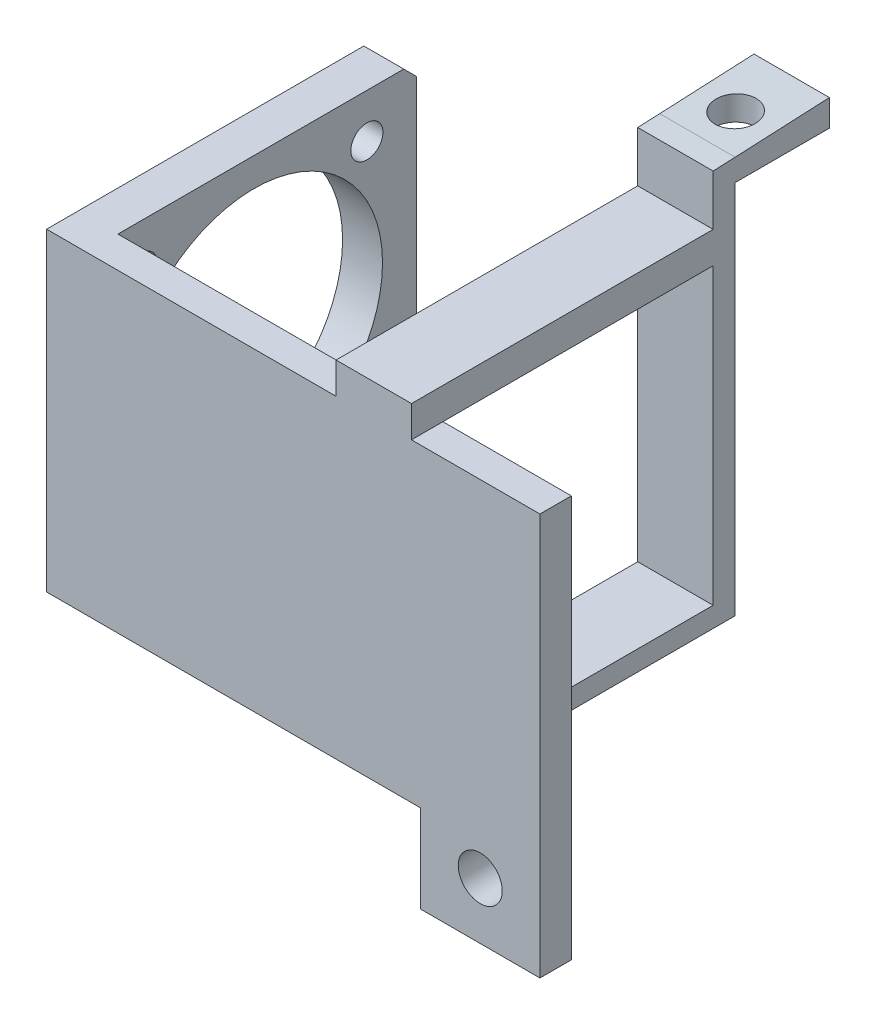
from build123d import *

# Parameters (mm, degrees)
BOSS_EXTRUDE1_DEPTH  = 5
SKETCH2_W            = 6.35
SKETCH2_H            = 50
BOSS_EXTRUDE2_DEPTH  = 52.48
CUT_EXTRUDE1_REACH   = 111.834
SKETCH3_R            = 20.44
SKETCH3_R_2          = 2.555
SKETCH3_W            = 5
SKETCH3_H            = 50
CUT_EXTRUDE2_REACH   = 113.895
SKETCH4_R            = 3.5
CUT_EXTRUDE6_REACH   = 113.895
SKETCH14_W           = 19
SKETCH14_H           = 15.316152196
SKETCH15_W           = 12
SKETCH15_H           = 3.2
BOSS_EXTRUDE7_DEPTH  = 46.5
BOSS_EXTRUDE8_REACH  = 107.356
SKETCH16_W           = 12
SKETCH16_H           = 3.5
SKETCH17_W           = 12
SKETCH17_H           = 3.5
BOSS_EXTRUDE9_DEPTH  = 15
CHAMFER2_SIZE        = 2
SKETCH22_W           = 12
SKETCH22_H           = 15
BOSS_EXTRUDE10_DEPTH = 0.72
CUT_EXTRUDE8_REACH   = 108.012
CUT_EXTRUDE7_REACH   = 125.963
SKETCH18_R           = 3.25
CIRPATTERN2_COUNT    = 2
CIRPATTERN2_ANGLE    = 90
BOSS_EXTRUDE11_REACH = 120.448
SKETCH24_W           = 12
SKETCH24_H           = 5


with BuildPart() as part:
    # Sketch1 → Boss-Extrude1 (new body)
    with BuildSketch(Plane.XY):
        Polygon((0, 0), (0, 50), (46.06, 50), (46.06, 55), (58.06, 55), (58.06, 50), (59.5, 50), (59.5, 64.061014889), (78.5, 64.061014889), (78.5, -13.938985111), (59.5, -13.938985111), (59.5, 0), align=None)
    extrude(amount=BOSS_EXTRUDE1_DEPTH)

    # Sketch2 → Boss-Extrude2 (add)
    with BuildSketch(Plane(origin=(0, 0, 0), x_dir=(-1, 0, 0), z_dir=(0, 0, -1))):
        with Locations((-3.175, 25)):
            Rectangle(SKETCH2_W, SKETCH2_H)
    extrude(amount=BOSS_EXTRUDE2_DEPTH)

    # Sketch3 → Cut-Extrude1 (cut, up to next)
    with BuildSketch(Plane(origin=(6.35, 0, 0), x_dir=(0, 0, -1), z_dir=(1, 0, 0)), mode=Mode.PRIVATE) as cut_extrude1_sk1:
        with Locations((21.66, 25)):
            Circle(SKETCH3_R)
    cut_extrude1_tool1 = extrude(cut_extrude1_sk1.sketch, amount=-CUT_EXTRUDE1_REACH, mode=Mode.PRIVATE) & part.part
    # Sketch3 → Cut-Extrude1 (cut, up to next)
    with BuildSketch(Plane(origin=(6.35, 0, 0), x_dir=(0, 0, -1), z_dir=(1, 0, 0)), mode=Mode.PRIVATE) as cut_extrude1_sk2:
        with Locations((3.695, 42.955)):
            Circle(SKETCH3_R_2)
    cut_extrude1_tool2 = extrude(cut_extrude1_sk2.sketch, amount=-CUT_EXTRUDE1_REACH, mode=Mode.PRIVATE) & part.part
    # Sketch3 → Cut-Extrude1 (cut, up to next)
    with BuildSketch(Plane(origin=(6.35, 0, 0), x_dir=(0, 0, -1), z_dir=(1, 0, 0)), mode=Mode.PRIVATE) as cut_extrude1_sk3:
        with Locations((39.615, 7.045)):
            Circle(SKETCH3_R_2)
    cut_extrude1_tool3 = extrude(cut_extrude1_sk3.sketch, amount=-CUT_EXTRUDE1_REACH, mode=Mode.PRIVATE) & part.part
    # Sketch3 → Cut-Extrude1 (cut, up to next)
    with BuildSketch(Plane(origin=(6.35, 0, 0), x_dir=(0, 0, -1), z_dir=(1, 0, 0)), mode=Mode.PRIVATE) as cut_extrude1_sk4:
        with Locations((49.98, 25)):
            Rectangle(SKETCH3_W, SKETCH3_H)
    cut_extrude1_tool4 = extrude(cut_extrude1_sk4.sketch, amount=-CUT_EXTRUDE1_REACH, mode=Mode.PRIVATE) & part.part
    cut_extrude1_1 = cut_extrude1_tool1.solids().sort_by_distance((6.35, 25, -21.66))[0]
    add(cut_extrude1_1, mode=Mode.SUBTRACT)
    cut_extrude1_2 = cut_extrude1_tool2.solids().sort_by_distance((6.35, 42.955, -3.695))[0]
    add(cut_extrude1_2, mode=Mode.SUBTRACT)
    cut_extrude1_3 = cut_extrude1_tool3.solids().sort_by_distance((6.35, 7.045, -39.615))[0]
    add(cut_extrude1_3, mode=Mode.SUBTRACT)
    cut_extrude1_4 = cut_extrude1_tool4.solids().sort_by_distance((6.35, 25, -49.98))[0]
    add(cut_extrude1_4, mode=Mode.SUBTRACT)
    cut_extrude1 = cut_extrude1_1 + cut_extrude1_2 + cut_extrude1_3 + cut_extrude1_4  # Cut-Extrude1 as one shape, for the pattern or mirror that repeats it

    # Sketch4 → Cut-Extrude2 (cut, up to next)
    with BuildSketch(Plane(origin=(0, 0, 0), x_dir=(-1, 0, 0), z_dir=(0, 0, -1)), mode=Mode.PRIVATE) as cut_extrude2_sk1:
        with Locations((-69, 55.061014889)):
            Circle(SKETCH4_R)
    cut_extrude2_tool1 = extrude(cut_extrude2_sk1.sketch, amount=-CUT_EXTRUDE2_REACH, mode=Mode.PRIVATE) & part.part
    # Sketch4 → Cut-Extrude2 (cut, up to next)
    with BuildSketch(Plane(origin=(0, 0, 0), x_dir=(-1, 0, 0), z_dir=(0, 0, -1)), mode=Mode.PRIVATE) as cut_extrude2_sk2:
        with Locations((-69, -4.938985111)):
            Circle(SKETCH4_R)
    cut_extrude2_tool2 = extrude(cut_extrude2_sk2.sketch, amount=-CUT_EXTRUDE2_REACH, mode=Mode.PRIVATE) & part.part
    add(cut_extrude2_tool1.solids().sort_by_distance((69, 55.061015, 0))[0], mode=Mode.SUBTRACT)
    add(cut_extrude2_tool2.solids().sort_by_distance((69, -4.938985, 0))[0], mode=Mode.SUBTRACT)

    # Sketch14 → Cut-Extrude6 (cut, up to next)
    with BuildSketch(Plane(origin=(0, 0, 0), x_dir=(-1, 0, 0), z_dir=(0, 0, -1)), mode=Mode.PRIVATE) as cut_extrude6_sk1:
        with Locations((-69, 57.658076098)):
            Rectangle(SKETCH14_W, SKETCH14_H)
    cut_extrude6_tool1 = extrude(cut_extrude6_sk1.sketch, amount=-CUT_EXTRUDE6_REACH, mode=Mode.PRIVATE) & part.part
    add(cut_extrude6_tool1.solids().sort_by_distance((69, 57.658076, 0))[0], mode=Mode.SUBTRACT)

    # Sketch15 → Boss-Extrude7 (add)
    with BuildSketch(Plane(origin=(0, 0, 0), x_dir=(-1, 0, 0), z_dir=(0, 0, -1))):
        with Locations((-52.06, 1.6)):
            Rectangle(SKETCH15_W, SKETCH15_H)
    extrude(amount=BOSS_EXTRUDE7_DEPTH)

    # Boss-Extrude8: up to this plane
    boss_extrude8_end = Plane(origin=(166.832994776, 64.085435133, -66.619565524), z_dir=(-1.1416993347548052e-15, 0.9990256874715413, 0.04413247978546202))
    # Sketch16 → Boss-Extrude8 (add, up to the surface)
    with BuildSketch(Plane(origin=(0, 3.2, 0), x_dir=(1, 0, 0), z_dir=(0, 1, 0)), mode=Mode.PRIVATE) as boss_extrude8_sk1:
        with Locations((52.06, 44.75)):
            Rectangle(SKETCH16_W, SKETCH16_H)
    boss_extrude8_tool1 = split(extrude(boss_extrude8_sk1.sketch, amount=BOSS_EXTRUDE8_REACH, mode=Mode.PRIVATE), bisect_by=boss_extrude8_end, keep=Keep.BOTH, mode=Mode.PRIVATE)
    add(boss_extrude8_tool1.solids().sort_by_distance((52.06, 3.2, -44.75))[0])

    # Sketch17 → Boss-Extrude9 (add)
    with BuildSketch(Plane(origin=(0, 0, -46.5), x_dir=(-1, 0, 0), z_dir=(0, 0, -1))):
        with Locations((-52.06, 61.446642853)):
            Rectangle(SKETCH17_W, SKETCH17_H)
    extrude(amount=BOSS_EXTRUDE9_DEPTH)

    # Chamfer2
    chamfer2_edges = [part.edges().sort_by_distance(p)[0] for p in [
        (3.175, 0, -47.48),
        (3.175, 50, -47.48),
    ]]
    chamfer(chamfer2_edges, length=CHAMFER2_SIZE)

    # Sketch22 → Boss-Extrude10 (add)
    with BuildSketch(Plane(origin=(0, 63.196642853, 0), x_dir=(1, 0, 0), z_dir=(0, 1, 0))):
        with Locations((52.06, 54)):
            Rectangle(SKETCH22_W, SKETCH22_H)
    extrude(amount=BOSS_EXTRUDE10_DEPTH)

    # Sketch23 → Cut-Extrude8 (cut, up to next)
    with BuildSketch(Plane(origin=(58.06, 0, 0), x_dir=(0, 0, -1), z_dir=(1, 0, 0)), mode=Mode.PRIVATE) as cut_extrude8_sk1:
        Polygon((46.5, 63.916642853), (46.5, 63.196642853), (61.5, 63.916642853), align=None)
    cut_extrude8_tool1 = extrude(cut_extrude8_sk1.sketch, amount=-CUT_EXTRUDE8_REACH, mode=Mode.PRIVATE) & part.part
    add(cut_extrude8_tool1.solids().sort_by_distance((58.06, 63.676643, -51.5))[0], mode=Mode.SUBTRACT)

    # Cut-Extrude7: up to this plane
    cut_extrude7_end = Plane(origin=(-0.001, 63.196642853, -46.5), z_dir=(-2.1659106514416256e-15, -0.9988499868416298, -0.04794479936839813))
    # Sketch18 → Cut-Extrude7 (cut, up to the surface)
    with BuildSketch(Plane.XZ.offset(-59.696642853), mode=Mode.PRIVATE) as cut_extrude7_sk1:
        with Locations(Location((52.06, -52.57, 0), (0, 0, 270))):
            Circle(SKETCH18_R)
    cut_extrude7_tool1 = split(extrude(cut_extrude7_sk1.sketch, amount=-CUT_EXTRUDE7_REACH, mode=Mode.PRIVATE), bisect_by=cut_extrude7_end, keep=Keep.BOTH, mode=Mode.PRIVATE)
    add(cut_extrude7_tool1.solids().sort_by_distance((52.06, 59.696643, -52.57))[0], mode=Mode.SUBTRACT)

    # CirPattern2: Cut-Extrude1 ×2 about axis
    cirpattern2_axis = Axis((0, 25, -21.66), (-1, 0, 0))
    for i in range(1, CIRPATTERN2_COUNT):
        add(cut_extrude1.rotate(cirpattern2_axis, i * CIRPATTERN2_ANGLE / (CIRPATTERN2_COUNT - 1)), mode=Mode.SUBTRACT)

    # Sketch24 → Boss-Extrude11 (add, up to next)
    with BuildSketch(Plane(origin=(0, 0, 0), x_dir=(-1, 0, 0), z_dir=(0, 0, -1)), mode=Mode.PRIVATE) as boss_extrude11_sk1:
        with Locations((-52.06, 52.5)):
            Rectangle(SKETCH24_W, SKETCH24_H)
    boss_extrude11_tool1 = extrude(boss_extrude11_sk1.sketch, amount=BOSS_EXTRUDE11_REACH, mode=Mode.PRIVATE) - part.part
    add(boss_extrude11_tool1.solids().sort_by_distance((52.06, 52.5, 0))[0])


solid = part.part
